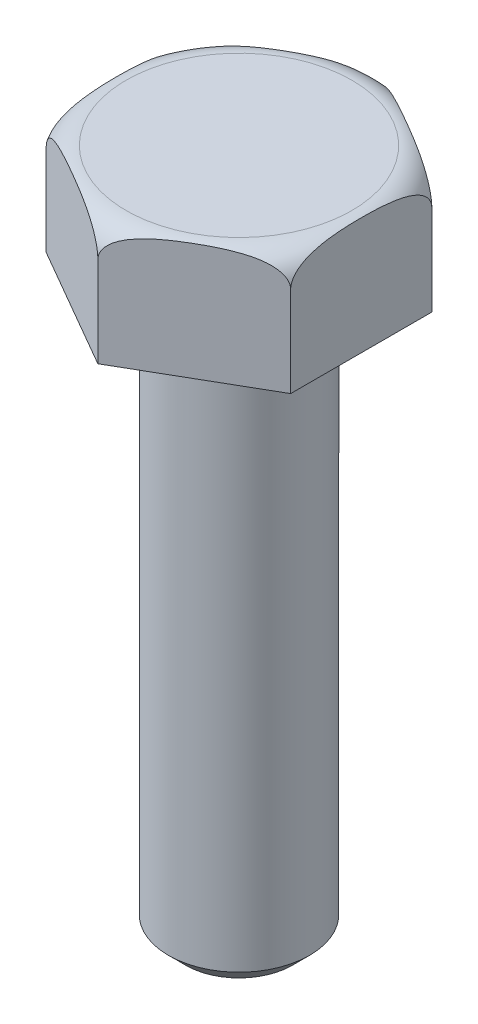
from build123d import *

# Parameters (mm, degrees)
EXTRUDE1_DEPTH = 5.334
SKETCH3_R      = 3.175
EXTRUDE2_DEPTH = 25.4
CHAMFER1_SIZE  = 0.762


with BuildPart() as part:
    # Sketch1 → Extrude1 (new body)
    with BuildSketch(Plane(origin=(0, 0, 0), x_dir=(1, 0, 0), z_dir=(0, 1, 0))):
        Polygon((0, 6.35), (-5.499261314, 3.175), (-5.499261314, -3.175), (0, -6.35), (5.499261314, -3.175), (5.499261314, 3.175), align=None)
    extrude(amount=EXTRUDE1_DEPTH)

    # Sketch3 → Extrude2 (add)
    with BuildSketch(Plane.XZ):
        Circle(SKETCH3_R)
    extrude(amount=EXTRUDE2_DEPTH)

    # Sketch2 → Cut-Revolve1 (revolve, cut)
    with BuildSketch(Plane(origin=(0, 0, 0), x_dir=(0, 0, -1), z_dir=(1, 0, 0))):
        with BuildLine():
            Line((5.08, 5.334), (6.35, 5.334))
            Line((6.35, 5.334), (6.35, 4.064))
            ThreePointArc((6.35, 4.064), (5.978025612, 4.962025612), (5.08, 5.334))
        make_face()
    revolve(axis=Axis((0, -25.4, 0), (0, 1, 0)), mode=Mode.SUBTRACT)

    # Chamfer1
    chamfer1_edges = [part.edges().sort_by_distance(p)[0] for p in [
        (-3.175, -25.4, 0),
    ]]
    chamfer(chamfer1_edges, length=CHAMFER1_SIZE)


solid = part.part
